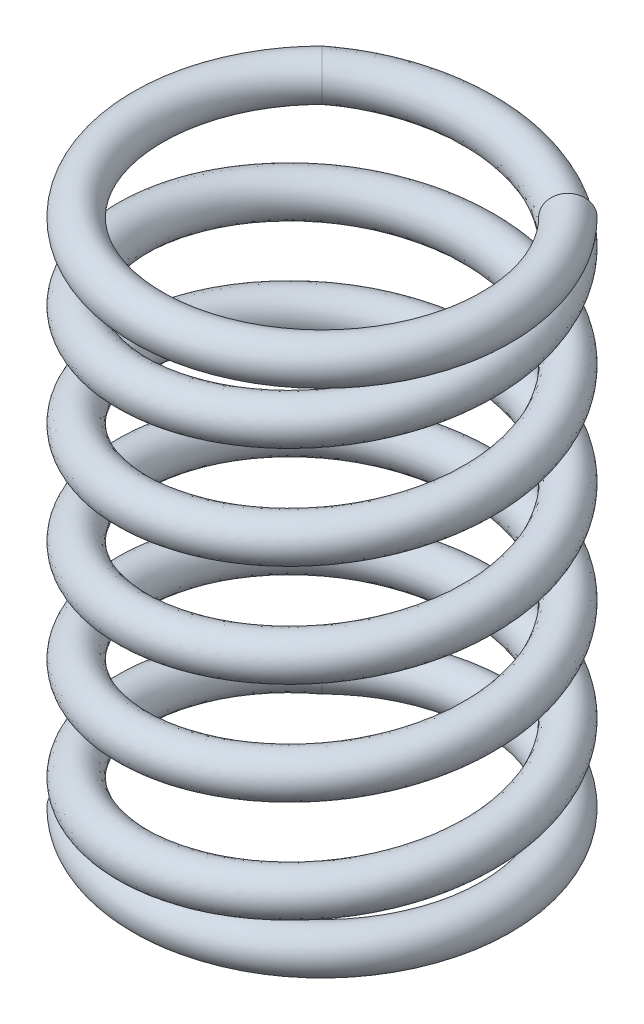
from build123d import *

# Parameters (mm, degrees)
BARRER1_PITCH       = 2
BARRER1_HEIGHT      = 10
BARRER1_RADIUS      = 3.405
BARRER1_START_ANGLE = -135
CROQUIS3_R          = 0.405
CROQUIS4_R          = 0.405
REVOLUCI_N1_ANGLE   = 270
CROQUIS6_R          = 0.405
REVOLUCI_N2_ANGLE   = 270


with BuildPart() as part:
    # Barrer1: sweep along a helix
    with BuildLine() as barrer1_path:
        add(Helix(BARRER1_PITCH, BARRER1_HEIGHT, BARRER1_RADIUS, center=(0, 0, 0), direction=(0, 1, 0), mode=Mode.PRIVATE).rotate(Axis((0, 0, 0), (0, 1, 0)), BARRER1_START_ANGLE))
    # Croquis3 → Barrer1 (sweep)
    with BuildSketch(Plane(origin=(0, 0, 0), x_dir=(0.707106781, 0, 0.707106781), z_dir=(-0.707106781, 0, 0.707106781))):
        with Locations((-3.405, 10)):
            Circle(CROQUIS3_R)
    sweep(path=barrer1_path.line, is_frenet=True)

    # Croquis4 → Revoluci_n1 (revolve)
    with BuildSketch(Plane(origin=(0, 0, 0), x_dir=(0.707106781, 0, 0.707106781), z_dir=(-0.707106781, 0, 0.707106781))):
        with Locations((-3.405, 10)):
            Circle(CROQUIS4_R)
    revolve(axis=Axis((0, 0, 0), (0, 1, 0)), revolution_arc=REVOLUCI_N1_ANGLE)

    # Croquis6 → Revoluci_n2 (revolve)
    with BuildSketch(Plane(origin=(0, 0, 0), x_dir=(-0.707106781, 0, -0.707106781), z_dir=(0.707106781, 0, -0.707106781))):
        with Locations((3.405, 0)):
            Circle(CROQUIS6_R)
    revolve(axis=Axis((0, 0, 0), (0, -1, 0)), revolution_arc=REVOLUCI_N2_ANGLE)


solid = part.part
